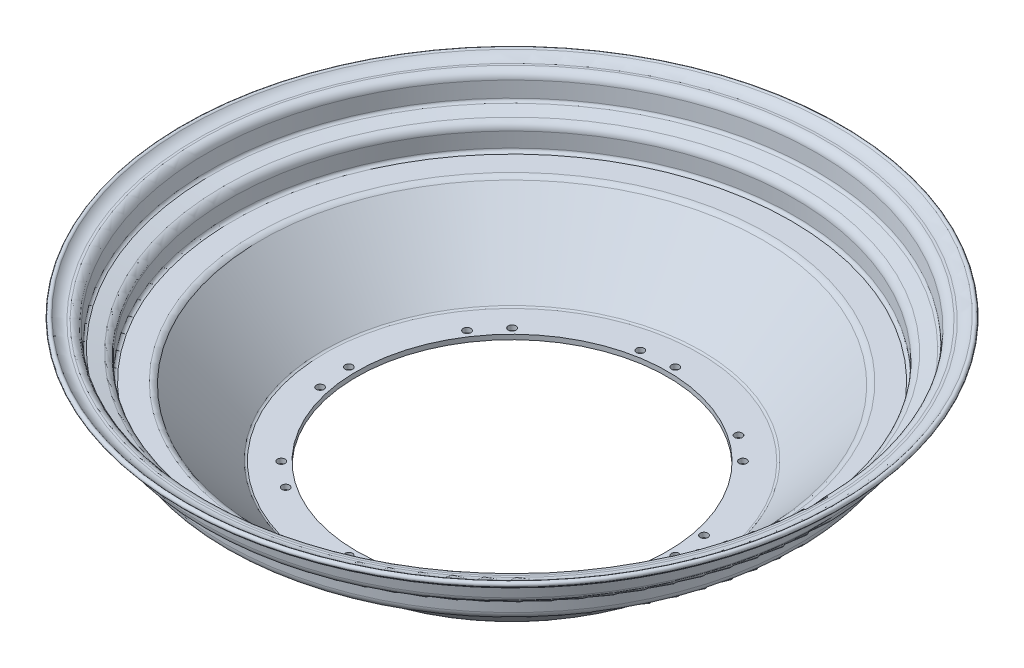
from build123d import *

# Parameters (mm, degrees)
SKETCH4_R               = 2.5
CUT_EXTRUDE3_DEPTH      = 42.652214206
CUT_EXTRUDE3_DEPTH_BACK = 46.006520078


with BuildPart() as part:
    # Sketch3 → Revolve2 (revolve)
    with BuildSketch(Plane.XY):
        with BuildLine():
            Line((-102, -45.006520078), (-122.759370887, -45.006520078))
            ThreePointArc((-122.759370887, -45.006520078), (-124.815857083, -44.580809144), (-126.534324491, -43.373649239))
            Line((-126.534324491, -43.373649239), (-167.290305146, 0))
            Line((-167.290305146, 0), (-182.873899467, 0))
            ThreePointArc((-182.873899467, 0), (-186.536712594, 1.517186873), (-188.053899467, 5.18))
            Line((-188.053899467, 5.18), (-188.053899467, 14.871478749))
            ThreePointArc((-188.053899467, 14.871478749), (-188.489033686, 16.116948575), (-189.605094554, 16.820471861))
            Line((-189.605094554, 16.820471861), (-198.018085623, 18.757775643))
            ThreePointArc((-198.018085623, 18.757775643), (-200.764119737, 20.406181688), (-202.015969434, 23.354201055))
            Line((-202.015969434, 23.354201055), (-202.86479408, 33.056311154))
            ThreePointArc((-202.86479408, 33.056311154), (-203.506003061, 34.356554342), (-204.857183476, 34.881999668))
            Line((-204.857183476, 34.881999668), (-206.357183476, 34.881999668))
            ThreePointArc((-206.357183476, 34.881999668), (-211.431068422, 35.980960403), (-215.620875017, 39.046501766))
            ThreePointArc((-215.620875017, 39.046501766), (-215.512219763, 41.2485817), (-213.310139829, 41.139926446))
            ThreePointArc((-213.310139829, 41.139926446), (-210.16007843, 38.862291983), (-206.357183499, 38.056999668))
            Line((-206.357183499, 38.056999668), (-204.857183476, 38.056999668))
            ThreePointArc((-204.857183476, 38.056999668), (-201.361004152, 36.697409886), (-199.701875913, 33.333030637))
            Line((-199.701875913, 33.333030637), (-198.852734468, 23.627299506))
            ThreePointArc((-198.852734468, 23.627299506), (-198.369394817, 22.489068091), (-197.309149985, 21.85261788))
            Line((-197.309149985, 21.85261788), (-188.896494742, 19.915391431))
            ThreePointArc((-188.896494742, 19.915391431), (-186.005897094, 18.09326612), (-184.878899467, 14.867499271))
            Line((-184.878899467, 14.867499271), (-184.878899467, 5.175))
            ThreePointArc((-184.878899467, 5.175), (-184.293113029, 3.760786438), (-182.878899467, 3.175))
            Line((-182.878899467, 3.175), (-168.157575681, 3.175))
            ThreePointArc((-168.157575681, 3.175), (-166.101089486, 2.749289067), (-164.382622077, 1.542129161))
            Line((-164.382622077, 1.542129161), (-124.165484741, -41.258068016))
            ThreePointArc((-124.165484741, -41.258068016), (-123.501983812, -41.724152922), (-122.707973697, -41.888520078))
            Line((-122.707973697, -41.888520078), (-102, -41.888520078))
            Line((-102, -41.888520078), (-102, -45.006520078))
        make_face()
    revolve(axis=Axis((0, 240.888952165, 0), (0, -1, 0)))

    # Sketch4 → Cut-Extrude3 (cut, two sides)
    with BuildSketch(Plane(origin=(0, 0, 0), x_dir=(1, 0, 0), z_dir=(0, 1, 0))) as cut_extrude3_sk:
        with Locations((0, 107)):
            Circle(SKETCH4_R)
        with Locations((-3884.181572475, -9484.24383099)):
            Circle(SKETCH4_R)
        with Locations((-13412.746254639, -13519.746254639)):
            Circle(SKETCH4_R)
        with Locations((-23003.990085629, -9635.564682164)):
            Circle(SKETCH4_R)
        with Locations((-27039.492509279, -107)):
            Circle(SKETCH4_R)
        with Locations((-23155.310936803, 9484.24383099)):
            Circle(SKETCH4_R)
        with Locations((-13626.746254639, 13519.746254639)):
            Circle(SKETCH4_R)
        with Locations((-4035.502423649, 9635.564682164)):
            Circle(SKETCH4_R)
        with Locations((-20.874664456, 104.944025003)):
            Circle(SKETCH4_R)
        with Locations((-3900.395983129, -9470.93700806)):
            Circle(SKETCH4_R)
        with Locations((-13414.802229636, -13498.871590184)):
            Circle(SKETCH4_R)
        with Locations((-22990.6832627, -9619.35027151)):
            Circle(SKETCH4_R)
        with Locations((-27018.617844823, -104.944025003)):
            Circle(SKETCH4_R)
        with Locations((-23139.096526149, 9470.93700806)):
            Circle(SKETCH4_R)
        with Locations((-13624.690279642, 13498.871590184)):
            Circle(SKETCH4_R)
        with Locations((-4048.809246579, 9619.35027151)):
            Circle(SKETCH4_R)
        with Locations((75.660425587, 75.660425587)):
            Circle(SKETCH4_R)
        with Locations((59.446014933, 88.967248516)):
            Circle(SKETCH4_R)
        with Locations((107, 0)):
            Circle(SKETCH4_R)
        with Locations((104.944025003, 20.874664456)):
            Circle(SKETCH4_R)
        with Locations((75.660425587, -75.660425587)):
            Circle(SKETCH4_R)
        with Locations((88.967248516, -59.446014933)):
            Circle(SKETCH4_R)
        with Locations((0, -107)):
            Circle(SKETCH4_R)
        with Locations((20.874664456, -104.944025003)):
            Circle(SKETCH4_R)
        with Locations((-75.660425587, -75.660425587)):
            Circle(SKETCH4_R)
        with Locations((-59.446014933, -88.967248516)):
            Circle(SKETCH4_R)
        with Locations((-107, 0)):
            Circle(SKETCH4_R)
        with Locations((-104.944025003, -20.874664456)):
            Circle(SKETCH4_R)
        with Locations((-75.660425587, 75.660425587)):
            Circle(SKETCH4_R)
        with Locations((-88.967248516, 59.446014933)):
            Circle(SKETCH4_R)
    extrude(amount=CUT_EXTRUDE3_DEPTH, mode=Mode.SUBTRACT)
    extrude(cut_extrude3_sk.sketch, amount=-CUT_EXTRUDE3_DEPTH_BACK, mode=Mode.SUBTRACT)


solid = part.part
